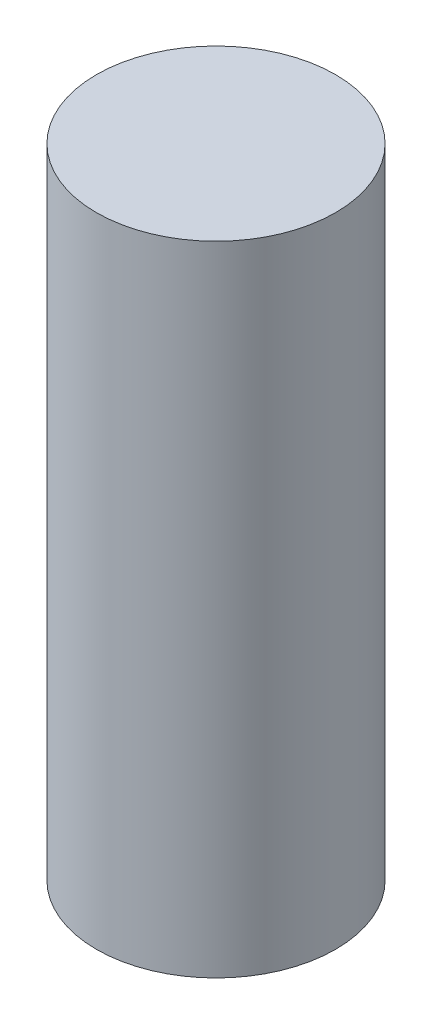
from build123d import *

# Parameters (mm, degrees)
SKETCH1_R        = 2.38
DOWEL_BODY_DEPTH = 12.7


with BuildPart() as part:
    # Sketch1 → dowel_body (new body)
    with BuildSketch(Plane(origin=(0, 0, 0), x_dir=(1, 0, 0), z_dir=(0, 1, 0))):
        Circle(SKETCH1_R)
    extrude(amount=DOWEL_BODY_DEPTH)


solid = part.part
